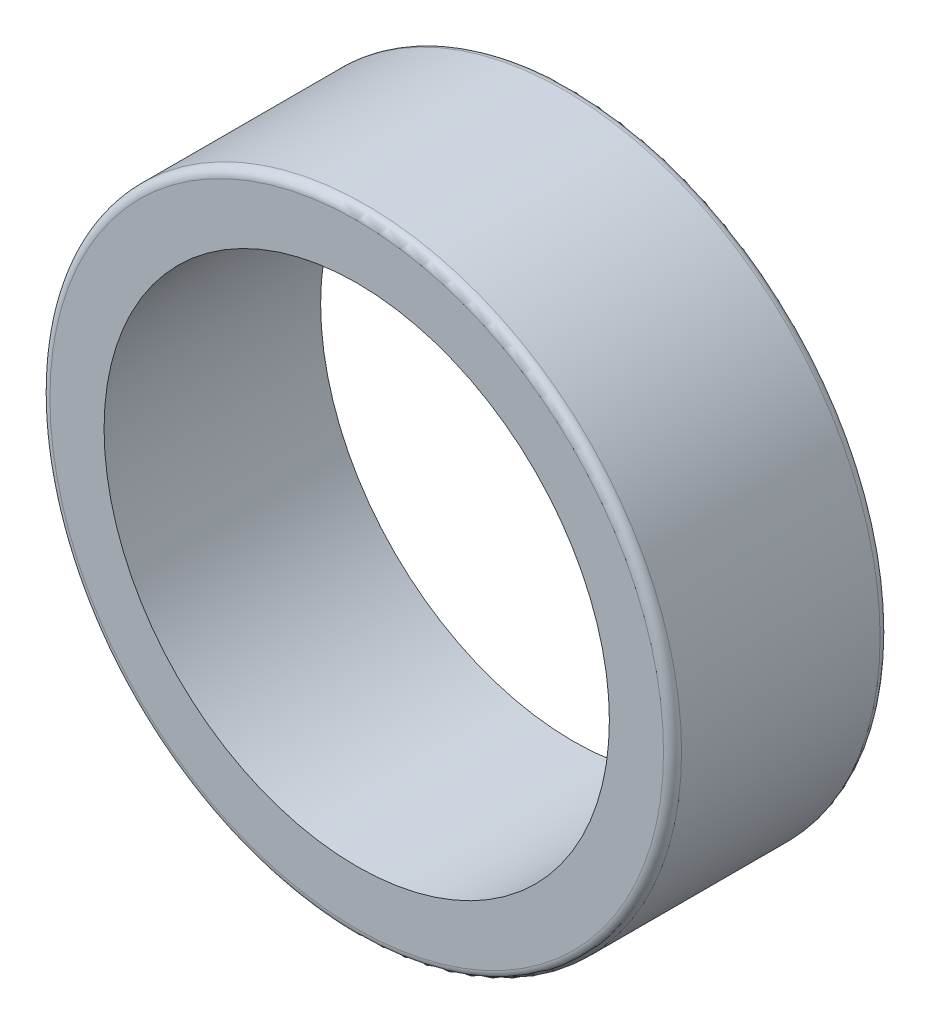
from build123d import *

# Parameters (mm, degrees)
ESQUISSE1_R        = 17.5
ESQUISSE1_R_2      = 14
BOSS_EXTRU_1_DEPTH = 12
CONG_1_R           = 0.5


with BuildPart() as part:
    # Esquisse1 → Boss.-Extru.1 (new body)
    with BuildSketch(Plane.XY):
        Circle(ESQUISSE1_R)
        Circle(ESQUISSE1_R_2, mode=Mode.SUBTRACT)
    extrude(amount=BOSS_EXTRU_1_DEPTH)

    # Congé1
    cong_1_edges = [part.edges().sort_by_distance(p)[0] for p in [
        (-17.5, 0, 0),
        (-17.5, 0, 12),
    ]]
    fillet(cong_1_edges, radius=CONG_1_R)


solid = part.part
